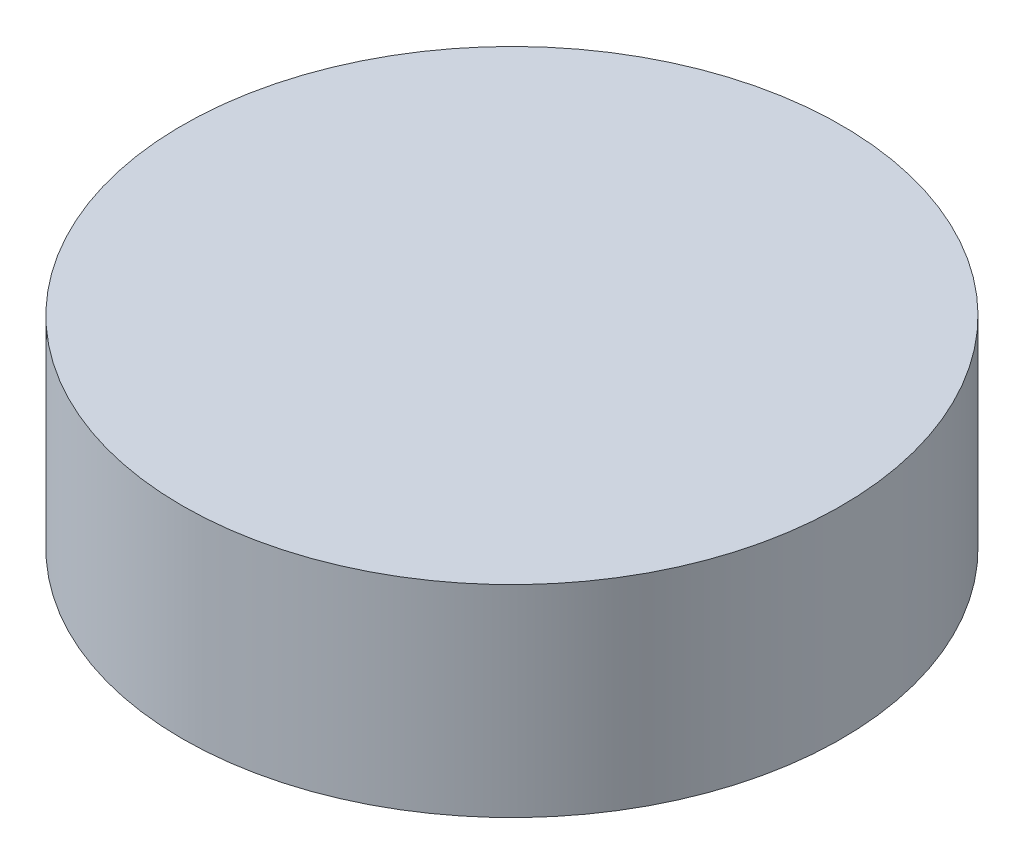
from build123d import *

# Parameters (mm, degrees)
SKETCH1_R           = 49
BOSS_EXTRUDE1_DEPTH = 30


with BuildPart() as part:
    # Sketch1 → Boss-Extrude1 (new body)
    with BuildSketch(Plane(origin=(0, 0, 0), x_dir=(1, 0, 0), z_dir=(0, 1, 0))):
        Circle(SKETCH1_R)
    extrude(amount=BOSS_EXTRUDE1_DEPTH)


solid = part.part
